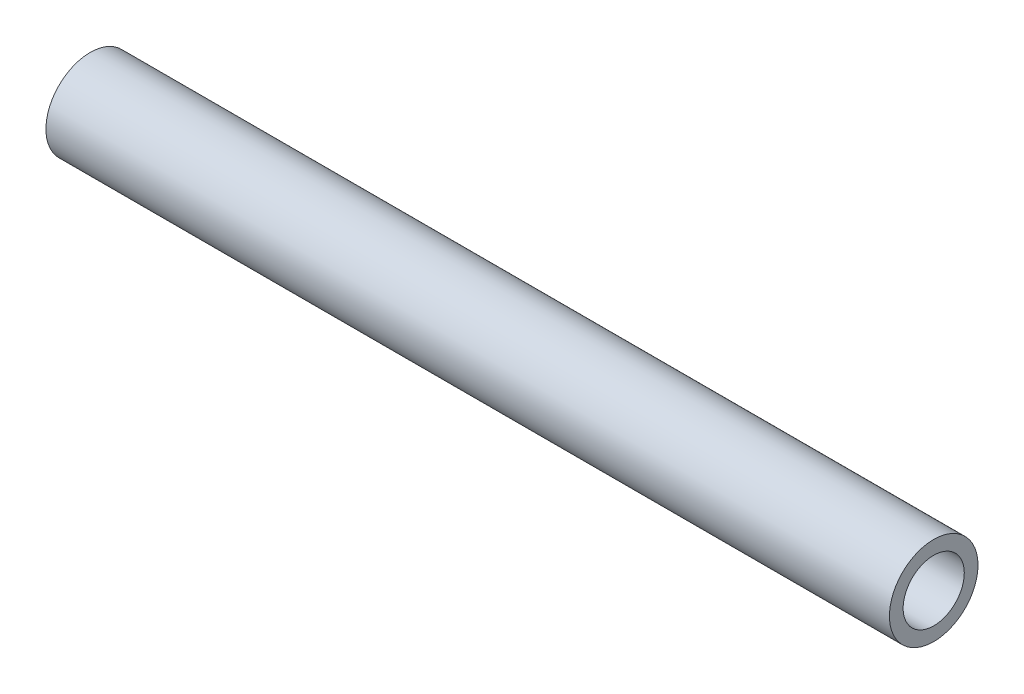
from build123d import *

# Parameters (mm, degrees)
SKETCH1_R           = 10.668
SKETCH1_R_2         = 7.366
BOSS_EXTRUDE1_DEPTH = 203.2


with BuildPart() as part:
    # Sketch1 → Boss-Extrude1 (new body)
    with BuildSketch(Plane(origin=(0, 0, 0), x_dir=(0, 0, -1), z_dir=(1, 0, 0))):
        Circle(SKETCH1_R)
        Circle(SKETCH1_R_2, mode=Mode.SUBTRACT)
    extrude(amount=-BOSS_EXTRUDE1_DEPTH)


solid = part.part
